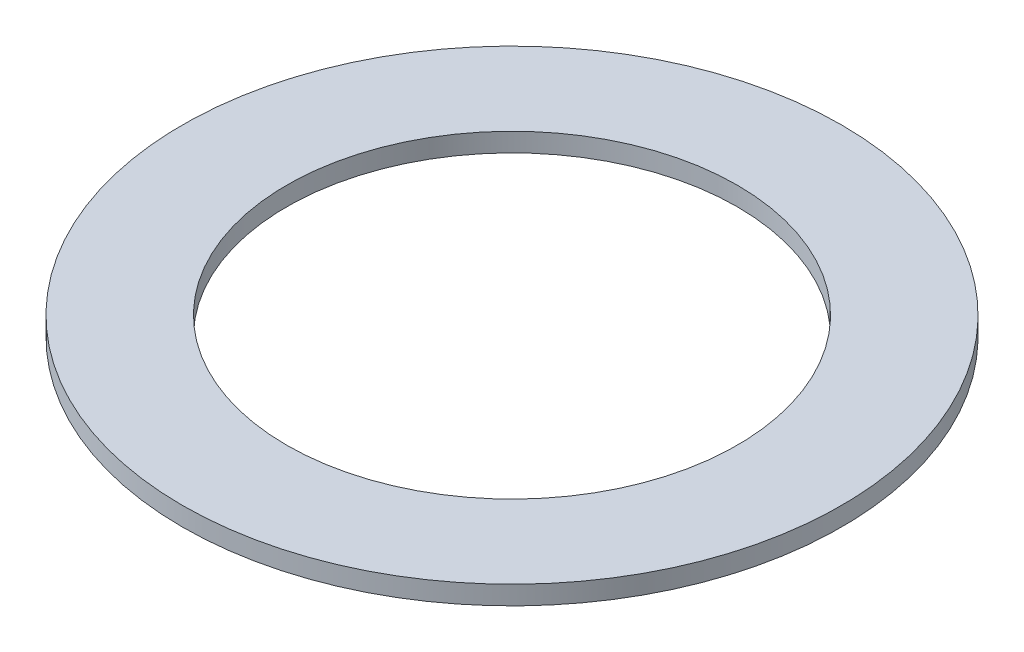
from build123d import *

# Parameters (mm, degrees)
SKETCH1_R           = 17.555096347
SKETCH1_R_2         = 12
BOSS_EXTRUDE1_DEPTH = 1


with BuildPart() as part:
    # Sketch1 → Boss-Extrude1 (new body)
    with BuildSketch(Plane(origin=(0, 0, 0), x_dir=(1, 0, 0), z_dir=(0, 1, 0))):
        Circle(SKETCH1_R)
        Circle(SKETCH1_R_2, mode=Mode.SUBTRACT)
    extrude(amount=BOSS_EXTRUDE1_DEPTH)


solid = part.part
